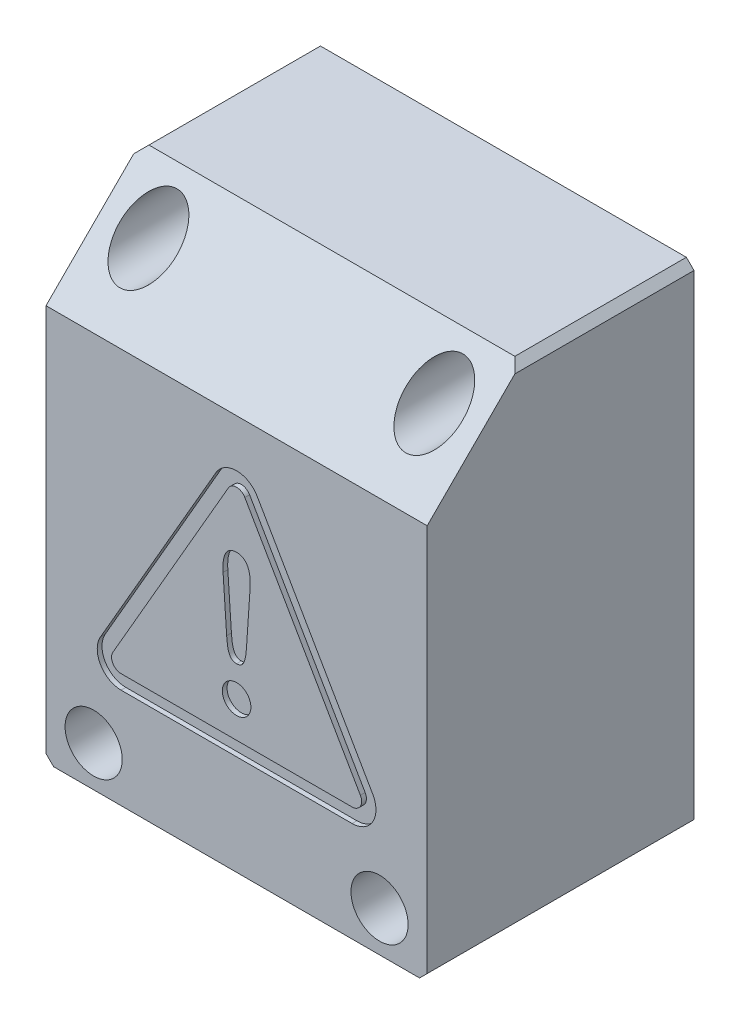
from build123d import *

# Parameters (mm, degrees)
BOSS_EXTRUDE1_DEPTH                                 = 40
CUT_EXTRUDE1_DEPTH                                  = 38
BOSS_EXTRUDE2_REACH                                 = 22
SKETCH6_W                                           = 7.999999469
SKETCH6_H                                           = 7.25
BOSS_EXTRUDE3_REACH                                 = 22
SKETCH7_W                                           = 7.999999468
SKETCH7_H                                           = 7.25
SKETCH8_W                                           = 7.999999727
SKETCH8_H                                           = 7.25
BOSS_EXTRUDE4_DEPTH                                 = 19
SKETCH9_W                                           = 7.999999728
SKETCH9_H                                           = 7.25
BOSS_EXTRUDE5_DEPTH                                 = 19
CUT_EXTRUDE4_DEPTH                                  = 0.5
BOSS_EXTRUDE6_DEPTH                                 = 0.5
CUT_EXTRUDE5_START                                  = 1.500005
CUT_EXTRUDE5_DEPTH                                  = 0.5
F_3_CLEARANCE_HOLE1_D                               = 3
F_3_CLEARANCE_HOLE1_DEPTH                           = 0.5
CBORE_FOR_4_BINDING_HEAD_MACHINE_SCREW1_D           = 3.2
CBORE_FOR_4_BINDING_HEAD_MACHINE_SCREW1_DEPTH       = 28
CBORE_FOR_4_BINDING_HEAD_MACHINE_SCREW1_CBORE_D     = 6
CBORE_FOR_4_BINDING_HEAD_MACHINE_SCREW1_CBORE_DEPTH = 19.000000001
CBORE_FOR_4_BINDING_HEAD_MACHINE_SCREW2_D           = 3.2
CBORE_FOR_4_BINDING_HEAD_MACHINE_SCREW2_DEPTH       = 25.25
CBORE_FOR_4_BINDING_HEAD_MACHINE_SCREW2_CBORE_D     = 6
CBORE_FOR_4_BINDING_HEAD_MACHINE_SCREW2_CBORE_DEPTH = 16.250000001
CHAMFER2_SIZE                                       = 0.8
FILLET1_R                                           = 1
FILLET2_R                                           = 4


with BuildPart() as part:
    # Sketch1 → Boss-Extrude1 (new body)
    with BuildSketch(Plane(origin=(19.860869514, 0, 0), x_dir=(0, 0, -1), z_dir=(1, 0, 0))):
        Polygon((0.020116779, -25.909092826), (0.020116779, 25.590907174), (-17.979883221, 25.590907174), (-27.979883221, 15.590907174), (-27.979883221, -25.909092826), align=None)
    extrude(amount=-BOSS_EXTRUDE1_DEPTH)

    # Sketch2 → Cut-Extrude1 (cut)
    with BuildSketch(Plane(origin=(-19.139130486, 0, 0), x_dir=(0, -1, 0), z_dir=(-1, 0, 0))):
        Polygon((-24.590907174, 17.565669658), (-24.590907174, -0.020116779), (24.909092826, -0.020116779), (24.909092826, 26.979883221), (-15.176693611, 26.979883221), align=None)
    extrude(amount=-CUT_EXTRUDE1_DEPTH, mode=Mode.SUBTRACT)

    # Sketch6 → Boss-Extrude2 (add, up to next)
    with BuildSketch(Plane(origin=(0, 0, 7.979883221), x_dir=(-1, 0, 0), z_dir=(0, 0, -1)), mode=Mode.PRIVATE) as boss_extrude2_sk1:
        with Locations((15.139130752, 20.965907174)):
            Rectangle(SKETCH6_W, SKETCH6_H)
    boss_extrude2_tool1 = extrude(boss_extrude2_sk1.sketch, amount=-BOSS_EXTRUDE2_REACH, mode=Mode.PRIVATE) - part.part
    add(boss_extrude2_tool1.solids().sort_by_distance((-15.139131, 20.965907, 7.979883))[0])

    # Sketch7 → Boss-Extrude3 (add, up to next)
    with BuildSketch(Plane(origin=(0, 0, 7.979883221), x_dir=(-1, 0, 0), z_dir=(0, 0, -1)), mode=Mode.PRIVATE) as boss_extrude3_sk1:
        with Locations((-14.86086978, 20.965907174)):
            Rectangle(SKETCH7_W, SKETCH7_H)
    boss_extrude3_tool1 = extrude(boss_extrude3_sk1.sketch, amount=-BOSS_EXTRUDE3_REACH, mode=Mode.PRIVATE) - part.part
    add(boss_extrude3_tool1.solids().sort_by_distance((14.86087, 20.965907, 7.979883))[0])

    # Sketch8 → Boss-Extrude4 (add)
    with BuildSketch(Plane(origin=(0, 0, 26.979883221), x_dir=(-1, 0, 0), z_dir=(0, 0, -1))):
        with Locations((-14.86086965, -21.284092826)):
            Rectangle(SKETCH8_W, SKETCH8_H)
    extrude(amount=BOSS_EXTRUDE4_DEPTH)

    # Sketch9 → Boss-Extrude5 (add)
    with BuildSketch(Plane(origin=(0, 0, 26.979883221), x_dir=(-1, 0, 0), z_dir=(0, 0, -1))):
        with Locations((15.139130622, -21.284092826)):
            Rectangle(SKETCH9_W, SKETCH9_H)
    extrude(amount=BOSS_EXTRUDE5_DEPTH)

    # Sketch10 → Cut-Extrude4 (cut)
    with BuildSketch(Plane.XY.offset(27.979883221)):
        with BuildLine():
            Line((14.150288676, -11.659092827), (2.025933023, 9.340907173))
            ThreePointArc((2.025933023, 9.340907173), (-0.139130487, 10.590907173), (-2.304193997, 9.340907173))
            Line((-2.304193997, 9.340907173), (-14.42854965, -11.659092827))
            ThreePointArc((-14.42854965, -11.659092827), (-14.42854965, -14.159092826), (-12.263486141, -15.409092826))
            Line((-12.263486141, -15.409092826), (11.985225167, -15.409092826))
            ThreePointArc((11.985225167, -15.409092826), (14.150288676, -14.159092826), (14.150288676, -11.659092827))
        make_face()
    extrude(amount=-CUT_EXTRUDE4_DEPTH, mode=Mode.SUBTRACT)

    # Sketch11 → Boss-Extrude6 (add)
    with BuildSketch(Plane.XY.offset(27.479883221)):
        with BuildLine():
            Line((-13.129511542, -12.409092827), (-1.005155889, 8.590907173))
            ThreePointArc((-1.005155889, 8.590907173), (-0.139130485, 9.090907174), (0.72689492, 8.590907173))
            Line((0.72689492, 8.590907173), (12.851250572, -12.409092827))
            ThreePointArc((12.851250572, -12.409092827), (12.851250572, -13.409092827), (11.985225169, -13.909092826))
            Line((11.985225169, -13.909092826), (-12.263486138, -13.909092826))
            ThreePointArc((-12.263486138, -13.909092826), (-13.129511542, -13.409092827), (-13.129511542, -12.409092827))
        make_face()
    extrude(amount=BOSS_EXTRUDE6_DEPTH)

    # Sketch12 → Cut-Extrude5 (cut)
    with BuildSketch(Plane.XY.offset(26.479878344).offset(CUT_EXTRUDE5_START)):
        with BuildLine():
            Line((-1.181805728, -4.919953815), (-1.557388601, 0.642194436))
            add(Edge.make_bspline(
                [(-1.557388601, 0.642194436), (-1.562255195, 0.726894151), (-1.57197876, 0.896126108), (-1.573630596, 1.150381332), (-1.563491274, 1.404367732), (-1.539477279, 1.657492298), (-1.498601615, 1.908446588), (-1.435950641, 2.155034423), (-1.347824447, 2.394209038), (-1.227947002, 2.620066875), (-1.070203444, 2.821498256), (-0.873757735, 2.98640743), (-0.644495445, 3.100925878), (-0.395458992, 3.166647074), (-0.224777297, 3.173588668), (-0.139130486, 3.177071908)],
                knots=[0, 0, 0, 0, 0.076934304, 0.153716488, 0.230489845, 0.307379808, 0.384178278, 0.460861998, 0.537777924, 0.614835636, 0.691825929, 0.768406055, 0.845421183, 0.922433493, 1, 1, 1, 1], degree=3))
            add(Edge.make_bspline(
                [(-0.139130486, 3.177071908), (-0.065510928, 3.174528216), (0.081440904, 3.169450757), (0.298073955, 3.121720242), (0.503386356, 3.037662683), (0.688981961, 2.914531923), (0.846742946, 2.757270627), (0.974882351, 2.575723676), (1.075136008, 2.378059028), (1.151690203, 2.170509138), (1.208454116, 1.957026535), (1.248786563, 1.740308946), (1.275266584, 1.522162803), (1.290343043, 1.303017743), (1.295405911, 1.083047008), (1.292059183, 0.862557831), (1.283440251, 0.71568476), (1.279127629, 0.642194436)],
                knots=[0, 0, 0, 0, 0.06668985, 0.133119456, 0.199920485, 0.266795101, 0.333669142, 0.400733876, 0.467442387, 0.534072191, 0.600968136, 0.667508068, 0.733796294, 0.800115594, 0.866606751, 0.933254524, 1, 1, 1, 1], degree=3))
            Line((1.279127629, 0.642194436), (0.903544756, -4.919953815))
            add(Edge.make_bspline(
                [(0.903544756, -4.919953815), (0.899040298, -4.98465678), (0.890033529, -5.114031861), (0.87358409, -5.307836112), (0.853415093, -5.501287734), (0.828449527, -5.694285405), (0.796710241, -5.88637973), (0.754944033, -6.076605831), (0.700731594, -6.263716972), (0.628895269, -6.444933688), (0.532938656, -6.614900625), (0.405346695, -6.763808252), (0.243240213, -6.874664069), (0.056441287, -6.938986541), (-0.073726294, -6.945537445), (-0.139130486, -6.948829022)],
                knots=[0, 0, 0, 0, 0.076936874, 0.153837066, 0.230708206, 0.307638675, 0.384651809, 0.461589354, 0.538534726, 0.615507305, 0.692327105, 0.769110055, 0.845963233, 0.922602462, 1, 1, 1, 1], degree=3))
            add(Edge.make_bspline(
                [(-0.139130486, -6.948829022), (-0.204192465, -6.945646156), (-0.334523872, -6.939270276), (-0.52166752, -6.874698808), (-0.684560534, -6.763099851), (-0.812386409, -6.613205645), (-0.908338892, -6.442461666), (-0.98006333, -6.260618976), (-1.034024433, -6.073329831), (-1.075624515, -5.883322576), (-1.107062911, -5.691940143), (-1.131842025, -5.499751942), (-1.151924163, -5.306932214), (-1.168322738, -5.113609534), (-1.177310111, -4.984524213), (-1.181805728, -4.919953815)],
                knots=[0, 0, 0, 0, 0.076983897, 0.154213255, 0.231303489, 0.308508561, 0.385703214, 0.462682138, 0.539884122, 0.61667812, 0.693280216, 0.76986989, 0.846510018, 0.923222027, 1, 1, 1, 1], degree=3))
        make_face()
    extrude(amount=-CUT_EXTRUDE5_DEPTH, mode=Mode.SUBTRACT)

    # #3 Clearance Hole1
    with Locations(Plane.XY.offset(27.979883221)):
        with Locations((-0.139130486, -10.159092826)):
            Hole(F_3_CLEARANCE_HOLE1_D / 2, depth=F_3_CLEARANCE_HOLE1_DEPTH)

    # CBORE for #4 Binding Head Machine Screw1
    with Locations(Plane.XY.offset(27.979883221)):
        with Locations((14.860869787, -21.659092826), (-15.139130758, -21.659092826)):
            CounterBoreHole(CBORE_FOR_4_BINDING_HEAD_MACHINE_SCREW1_D / 2, CBORE_FOR_4_BINDING_HEAD_MACHINE_SCREW1_CBORE_D / 2, CBORE_FOR_4_BINDING_HEAD_MACHINE_SCREW1_CBORE_DEPTH, depth=CBORE_FOR_4_BINDING_HEAD_MACHINE_SCREW1_DEPTH)

    # CBORE for #4 Binding Head Machine Screw2
    with Locations(Plane.XY.offset(25.229883221)):
        with Locations((-15.139131017, 21.340907174), (14.860870046, 21.340907174)):
            CounterBoreHole(CBORE_FOR_4_BINDING_HEAD_MACHINE_SCREW2_D / 2, CBORE_FOR_4_BINDING_HEAD_MACHINE_SCREW2_CBORE_D / 2, CBORE_FOR_4_BINDING_HEAD_MACHINE_SCREW2_CBORE_DEPTH, depth=CBORE_FOR_4_BINDING_HEAD_MACHINE_SCREW2_DEPTH)

    # Chamfer2
    chamfer2_edges = [part.edges().sort_by_distance(p)[0] for p in [
        (-20.139130486, 25.590907174, 8.979883221),
        (-20.139130486, -25.909092826, 13.979883221),
        (19.860869514, 25.590907174, 8.979883221),
        (19.860869514, -25.909092826, 13.979883221),
    ]]
    chamfer(chamfer2_edges, length=CHAMFER2_SIZE)

    # Fillet1
    fillet1_edges = [part.edges().sort_by_distance(p)[0] for p in [
        (-11.139131017, 24.590907174, 12.77277644),
        (-19.139130486, 17.340907174, 16.39777644),
        (10.860870046, 24.590907174, 12.77277644),
        (18.860869514, 17.340907174, 16.39777644),
        (10.860869787, -24.909092826, 17.479883221),
        (18.860869514, -17.659092826, 17.479883221),
        (-19.139130486, -17.659092826, 17.479883221),
        (-11.139130758, -24.909092826, 17.479883221),
    ]]
    fillet(fillet1_edges, radius=FILLET1_R)

    # Fillet2
    fillet2_edges = [part.edges().sort_by_distance(p)[0] for p in [
        (-11.139131017, 17.340907174, 16.39777644),
        (10.860870046, 17.340907174, 16.39777644),
        (10.860869787, -17.659092826, 17.479883221),
        (-11.139130758, -17.659092826, 17.479883221),
    ]]
    fillet(fillet2_edges, radius=FILLET2_R)


solid = part.part
